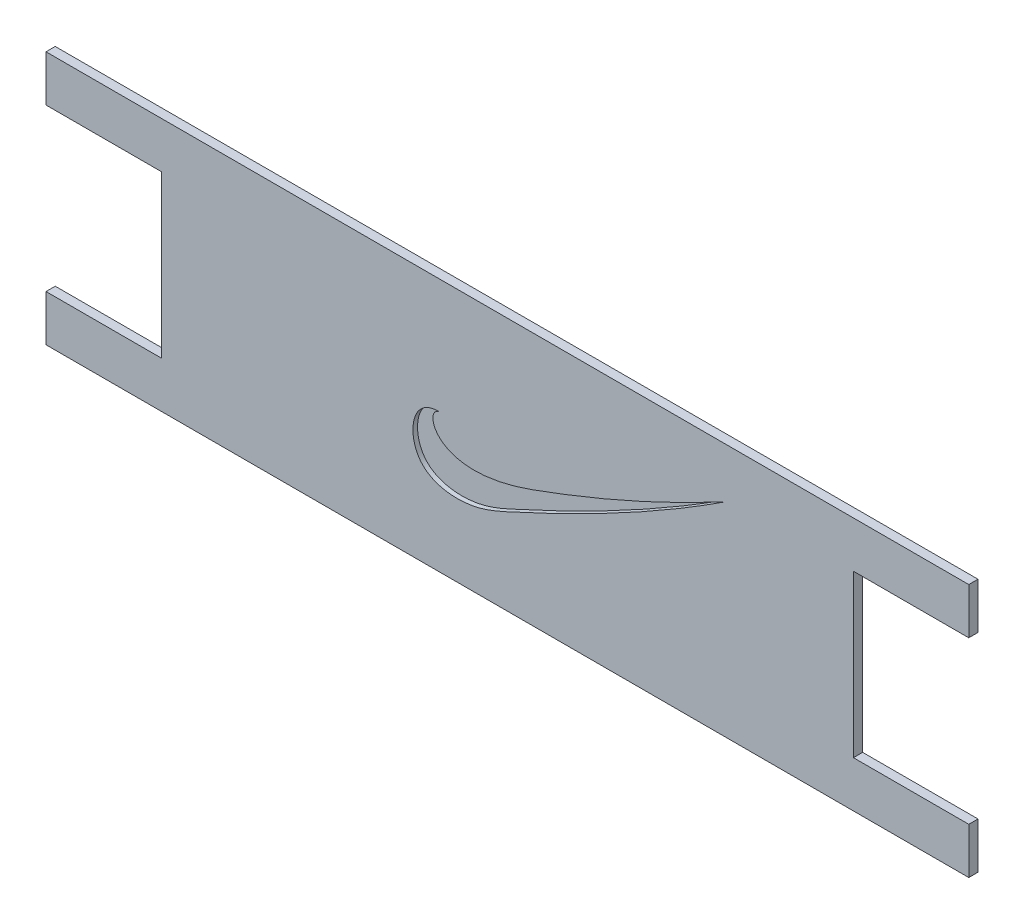
from build123d import *

# Parameters (mm, degrees)
BOSS_EXTRUDE1_DEPTH = 2
CUT_EXTRUDE1_DEPTH  = 1


with BuildPart() as part:
    # Sketch1 → Boss-Extrude1 (new body)
    with BuildSketch(Plane.XY):
        Polygon((-48.310810811, 14.243974201), (151.689189189, 14.243974201), (151.689189189, 4.243974201), (126.689189189, 4.243974201), (126.689189189, -30.756025799), (151.689189189, -30.756025799), (151.689189189, -40.756025799), (-48.310810811, -40.756025799), (-48.310810811, -30.756025799), (-23.310810811, -30.756025799), (-23.310810811, 4.243974201), (-48.310810811, 4.243974201), align=None)
    extrude(amount=BOSS_EXTRUDE1_DEPTH)

    # Sketch3 → Cut-Extrude1 (cut)
    with BuildSketch(Plane.XY.offset(2)):
        with BuildLine():
            add(Edge.make_bspline(
                [(37.189484824, -10.718294686), (33.474166953, -10.624199422), (35.300627772, -23.216467907), (74.220048032, -9.046257892), (87.664897587, -2.594986042), (98.853365994, 3.337442933)],
                knots=[0, 0, 0, 0, 0.51776511, 0.592619661, 1, 1, 1, 1], degree=3))
            add(Edge.make_bspline(
                [(37.189484824, -10.718294686), (30.815944463, -10.332745105), (29.156875012, -24.169852988), (43.250186434, -25.85327449), (65.190161886, -16.178918043), (83.996504619, -6.384768657), (98.853365994, 3.337442933)],
                knots=[0, 0, 0, 0, 0.163170519, 0.29176393, 0.388322168, 1, 1, 1, 1], degree=3))
        make_face()
    extrude(amount=-CUT_EXTRUDE1_DEPTH, mode=Mode.SUBTRACT)


solid = part.part
